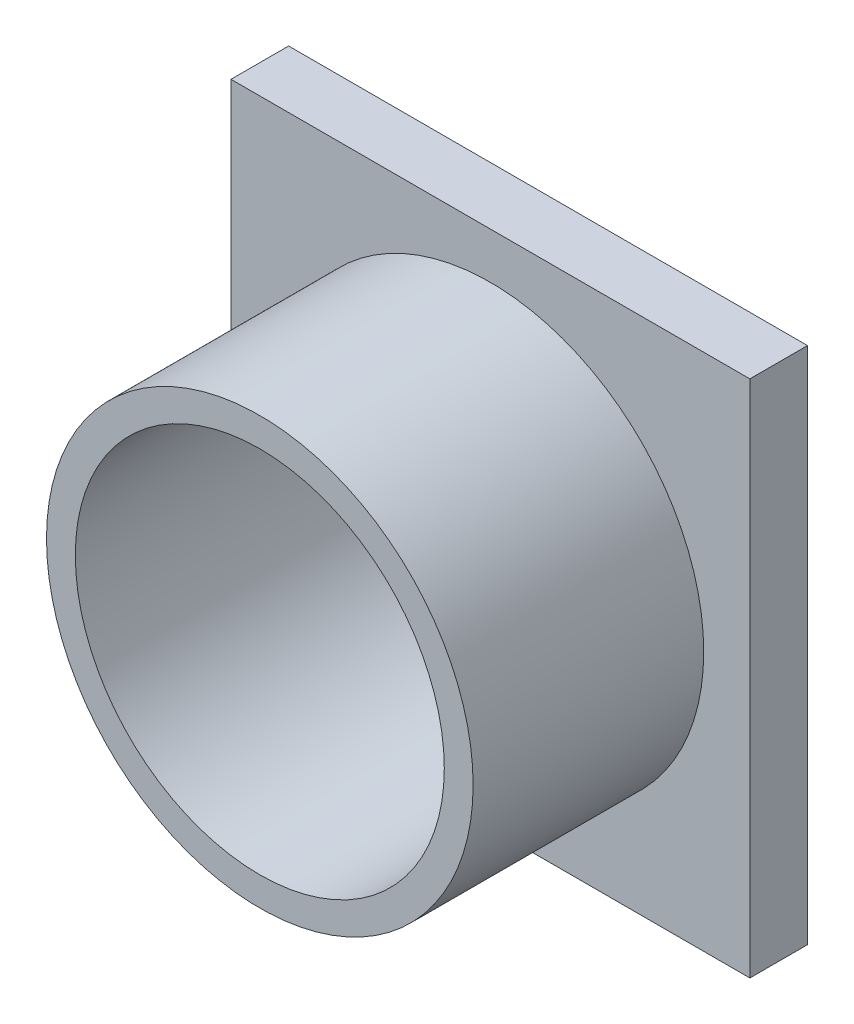
from build123d import *

# Parameters (mm, degrees)
ESQUISSE1_W        = 45
ESQUISSE1_H        = 45
ESQUISSE1_R        = 16
BOSS_EXTRU_1_DEPTH = 5
ESQUISSE2_R        = 18.5
ESQUISSE2_R_2      = 16
BOSS_EXTRU_2_DEPTH = 20
ESQUISSE3_W        = 5
ESQUISSE3_H        = 4
BOSS_EXTRU_3_DEPTH = 3


with BuildPart() as part:
    # Esquisse1 → Boss.-Extru.1 (new body)
    with BuildSketch(Plane.XY):
        Rectangle(ESQUISSE1_W, ESQUISSE1_H)
        Circle(ESQUISSE1_R, mode=Mode.SUBTRACT)
    extrude(amount=BOSS_EXTRU_1_DEPTH)

    # Esquisse2 → Boss.-Extru.2 (add)
    with BuildSketch(Plane.XY.offset(5)):
        Circle(ESQUISSE2_R)
        Circle(ESQUISSE2_R_2, mode=Mode.SUBTRACT)
    extrude(amount=BOSS_EXTRU_2_DEPTH)

    # Esquisse3 → Boss.-Extru.3 (add)
    with BuildSketch(Plane(origin=(0, 0, 0), x_dir=(-1, 0, 0), z_dir=(0, 0, -1))):
        with Locations((16.5, 17)):
            Rectangle(ESQUISSE3_W, ESQUISSE3_H)
        with Locations((-16.5, 17)):
            Rectangle(ESQUISSE3_W, ESQUISSE3_H)
        with Locations((-16.5, -17)):
            Rectangle(ESQUISSE3_W, ESQUISSE3_H)
        with Locations((16.5, -17)):
            Rectangle(ESQUISSE3_W, ESQUISSE3_H)
    extrude(amount=BOSS_EXTRU_3_DEPTH)


solid = part.part
